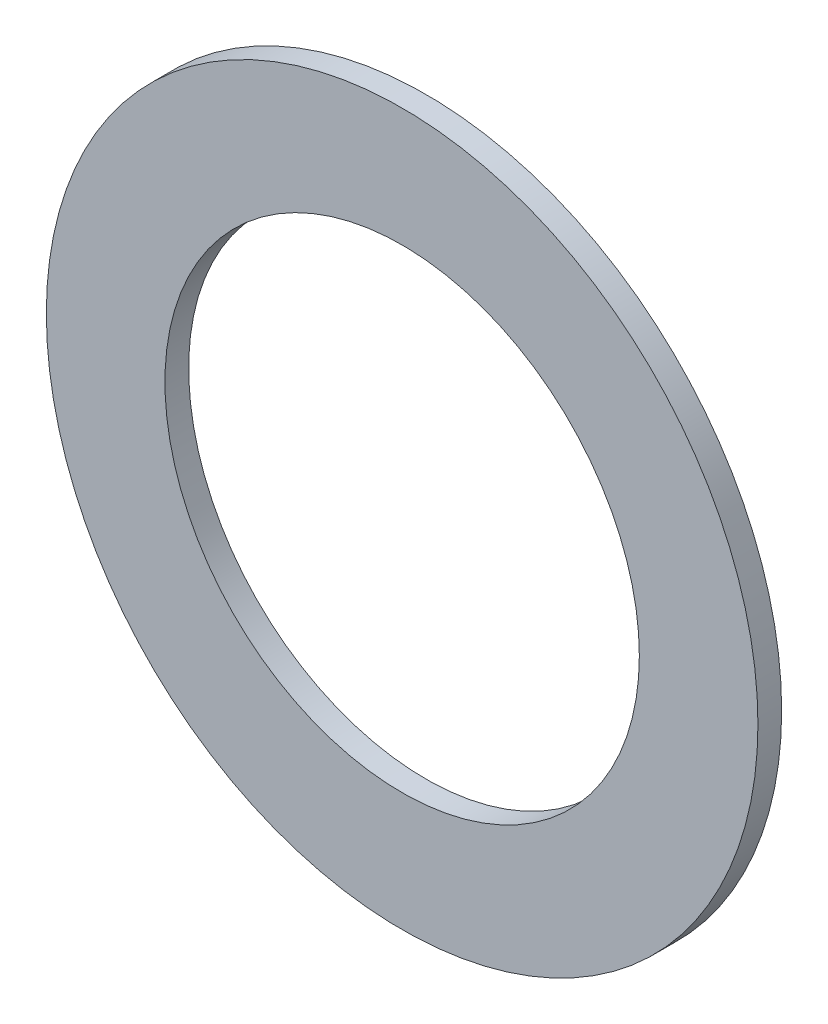
from build123d import *

# Parameters (mm, degrees)
SKETCH_1_R      = 3
SKETCH_1_R_2    = 2
EXTRUDE_1_DEPTH = 0.2


with BuildPart() as part:
    # 草图1 → 凸台-拉伸1 (new body)
    with BuildSketch(Plane.XY):
        Circle(SKETCH_1_R)
        Circle(SKETCH_1_R_2, mode=Mode.SUBTRACT)
    extrude(amount=EXTRUDE_1_DEPTH)


solid = part.part
